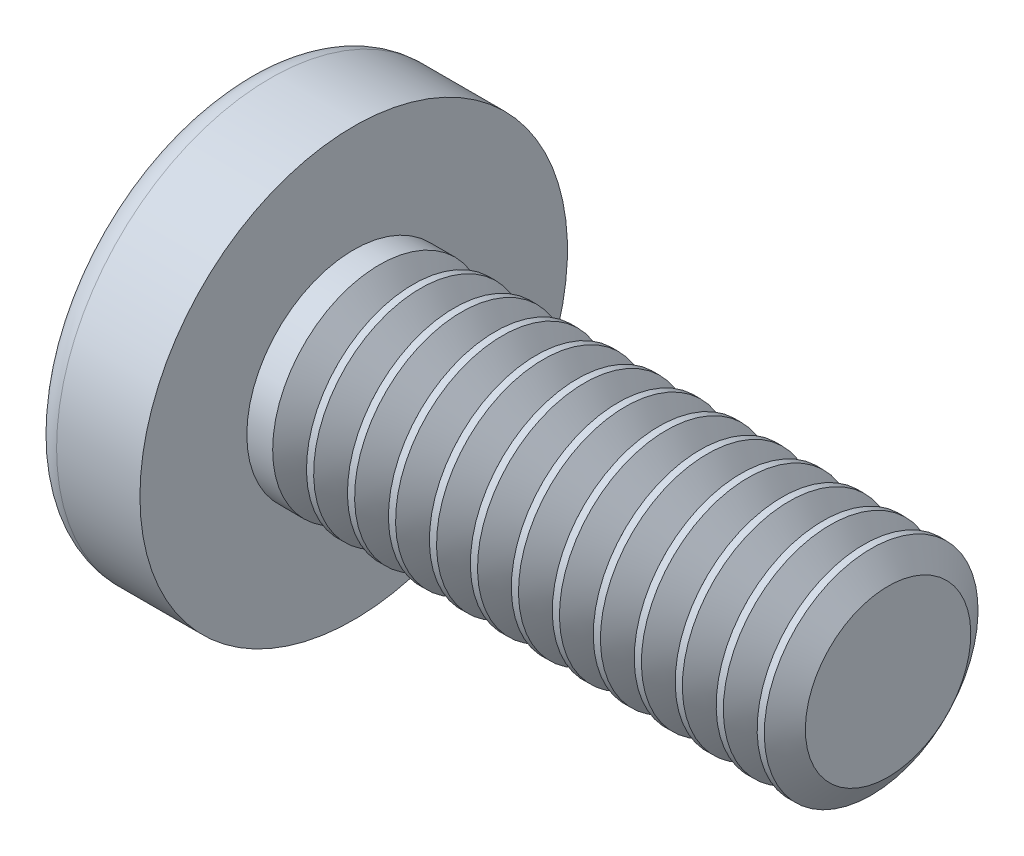
from build123d import *

# Parameters (mm, degrees)
SKETCH3_W         = 0.48
SKETCH3_H         = 1.82
SKETCH4_W         = 0.24
SKETCH4_H         = 0.24
CIRPATTERN1_COUNT = 2
CIRPATTERN1_ANGLE = 90
THDSCHPAT_COUNT   = 13
THDSCHPAT_PITCH   = 0.383333333


with BuildPart() as part:
    # BodySke → Base-Revolve (revolve)
    with BuildSketch(Plane.XY):
        with BuildLine():
            Line((1.6, 1), (1.6, 2))
            Line((1.6, 2), (0.820084035, 2))
            ThreePointArc((0.820084035, 2), (0.712029995, 1.974299613), (0.627117876, 1.902702703))
            ThreePointArc((0.627117876, 1.902702703), (0.160820604, 1.001692868), (0, 0))
            Line((0, 0), (6.6, 0))
            Line((6.6, 0), (6.6, 1))
            Line((6.6, 1), (1.6, 1))
        make_face()
    revolve(axis=Axis((-25.4, 0, 0), (1, 0, 0)))

    # Sketch3 → Cut-Loft1 section 0
    with BuildSketch(Plane(origin=(0, 0, 0), x_dir=(0, 0, -1), z_dir=(1, 0, 0))):
        Rectangle(SKETCH3_W, SKETCH3_H)
    # Sketch4 → Cut-Loft1 section 1
    with BuildSketch(Plane(origin=(1.19, 0, 0), x_dir=(0, 0, -1), z_dir=(1, 0, 0))):
        Rectangle(SKETCH4_W, SKETCH4_H)
    cut_loft1 = loft(mode=Mode.SUBTRACT)

    # CirPattern1: Cut-Loft1 ×2 about axis
    cirpattern1_axis = Axis((0, 0, 0), (1, 0, 0))
    for i in range(1, CIRPATTERN1_COUNT):
        add(cut_loft1.rotate(cirpattern1_axis, i * CIRPATTERN1_ANGLE / (CIRPATTERN1_COUNT - 1)), mode=Mode.SUBTRACT)

    # ThdSchSke → ThreadSchematic (revolve, cut)
    with BuildSketch(Plane.XY):
        Polygon((2, -0.774), (1.841753096, -1), (1.841753096, -1.25), (2.158246904, -1.25), (2.158246904, -1), align=None)
    threadschematic = revolve(axis=Axis((-3.175, 0, 0), (1, 0, 0)), mode=Mode.SUBTRACT)

    # ThdSchPat: ThreadSchematic ×13
    with Locations(*[(i * THDSCHPAT_PITCH, 0, 0) for i in range(1, THDSCHPAT_COUNT)]):
        add(threadschematic, mode=Mode.SUBTRACT)


solid = part.part
